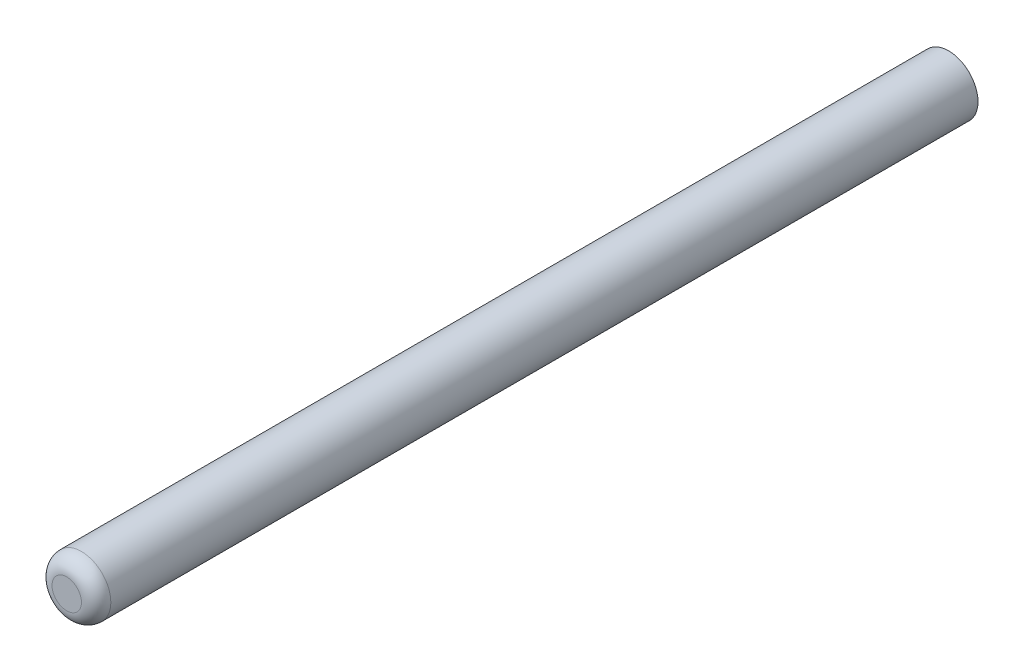
from build123d import *

# Parameters (mm, degrees)
SKETCH1_R           = 10
BOSS_EXTRUDE1_DEPTH = 300
FILLET1_R           = 5


with BuildPart() as part:
    # Sketch1 → Boss-Extrude1 (new body)
    with BuildSketch(Plane.XY):
        Circle(SKETCH1_R)
    extrude(amount=BOSS_EXTRUDE1_DEPTH)

    # Fillet1
    fillet1_edges = [part.edges().sort_by_distance(p)[0] for p in [
        (-10, 0, 300),
    ]]
    fillet(fillet1_edges, radius=FILLET1_R)


solid = part.part
